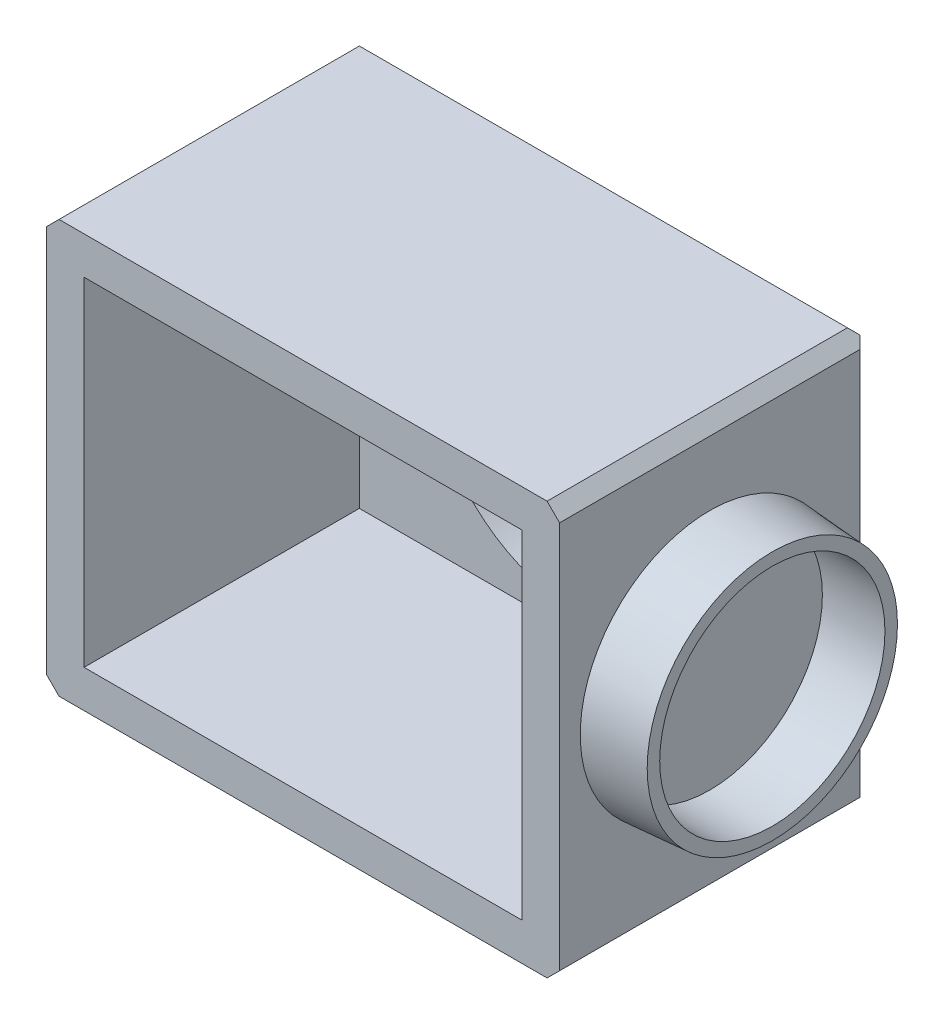
from build123d import *

# Parameters (mm, degrees)
SKETCH_1_W          = 41
SKETCH_1_H          = 33
SKETCH_1_W_2        = 35
SKETCH_1_H_2        = 27
EXTRUDE_1_DEPTH     = 22
SKETCH_6_W          = 41
SKETCH_6_H          = 33
EXTRUDE_1_2_DEPTH   = 3
SKETCH_7_R          = 12
CUT_EXTRUDE_1_DEPTH = 5
CHAMFER_1_SIZE      = 1
CHAMFER_2_SIZE      = 1
CHAMFER_3_SIZE      = 1
CHAMFER_4_SIZE      = 1
SKETCH_8_R          = 1.1
EXTRUDE_3_DEPTH     = 6
EXTRUDE_3_TAPER     = 3
CHAMFER_5_SIZE      = 1
CHAMFER_6_SIZE      = 1
CHAMFER_7_SIZE      = 1
CHAMFER_8_SIZE      = 1
SKETCH_9_R          = 10.35
EXTRUDE_4_DEPTH     = 5
EXTRUDE_4_TAPER     = 4
SKETCH_10_R         = 9
CUT_EXTRUDE_2_DEPTH = 5


with BuildPart() as part:
    # Эскиз1 → Extrude 1 (new body)
    with BuildSketch(Plane.XY):
        Rectangle(SKETCH_1_W, SKETCH_1_H)
        Rectangle(SKETCH_1_W_2, SKETCH_1_H_2, mode=Mode.SUBTRACT)
    extrude(amount=EXTRUDE_1_DEPTH)

    # Эскиз6 → Extrude 1 2 (add)
    with BuildSketch(Plane(origin=(0, 0, 0), x_dir=(-1, 0, 0), z_dir=(0, 0, -1))):
        Rectangle(SKETCH_6_W, SKETCH_6_H)
    extrude(amount=EXTRUDE_1_2_DEPTH)

    # Эскиз7 → Вырез-Вытянуть1 (cut)
    with BuildSketch(Plane(origin=(0, 0, -3), x_dir=(-1, 0, 0), z_dir=(0, 0, -1))):
        Circle(SKETCH_7_R)
    extrude(amount=-CUT_EXTRUDE_1_DEPTH, mode=Mode.SUBTRACT)

    # Фаска1
    chamfer_1_edges = [part.edges().sort_by_distance(p)[0] for p in [
        (0, 16.5, -3),
    ]]
    chamfer(chamfer_1_edges, length=CHAMFER_1_SIZE)

    # Фаска2
    chamfer_2_edges = [part.edges().sort_by_distance(p)[0] for p in [
        (20.5, -0.5, -3),
    ]]
    chamfer(chamfer_2_edges, length=CHAMFER_2_SIZE)

    # Фаска3
    chamfer_3_edges = [part.edges().sort_by_distance(p)[0] for p in [
        (-20.5, -0.5, -3),
    ]]
    chamfer(chamfer_3_edges, length=CHAMFER_3_SIZE)

    # Фаска4
    chamfer_4_edges = [part.edges().sort_by_distance(p)[0] for p in [
        (0, -16.5, -3),
    ]]
    chamfer(chamfer_4_edges, length=CHAMFER_4_SIZE)

    # Эскиз8 → Бобышка-Вытянуть3 (add)
    with BuildSketch(Plane.XY):
        with Locations((14.5, 0)):
            Circle(SKETCH_8_R)
        with Locations((-14.5, 0)):
            Circle(SKETCH_8_R)
    extrude(amount=EXTRUDE_3_DEPTH, taper=EXTRUDE_3_TAPER)

    # Фаска5
    chamfer_5_edges = [part.edges().sort_by_distance(p)[0] for p in [
        (-20.5, 16.5, 10),
    ]]
    chamfer(chamfer_5_edges, length=CHAMFER_5_SIZE)

    # Фаска6
    chamfer_6_edges = [part.edges().sort_by_distance(p)[0] for p in [
        (20.5, 16.5, 10),
    ]]
    chamfer(chamfer_6_edges, length=CHAMFER_6_SIZE)

    # Фаска7
    chamfer_7_edges = [part.edges().sort_by_distance(p)[0] for p in [
        (20.5, -16.5, 10),
    ]]
    chamfer(chamfer_7_edges, length=CHAMFER_7_SIZE)

    # Фаска8
    chamfer_8_edges = [part.edges().sort_by_distance(p)[0] for p in [
        (-20.5, -16.5, 10),
    ]]
    chamfer(chamfer_8_edges, length=CHAMFER_8_SIZE)

    # Эскиз9 → Бобышка-Вытянуть4 (add)
    with BuildSketch(Plane(origin=(20.5, 0, 0), x_dir=(0, 0, -1), z_dir=(1, 0, 0))):
        with Locations((-10, 0)):
            Circle(SKETCH_9_R)
    extrude(amount=EXTRUDE_4_DEPTH, taper=EXTRUDE_4_TAPER)

    # Эскиз10 → Вырез-Вытянуть2 (cut)
    with BuildSketch(Plane(origin=(25.5, 0, 0), x_dir=(0, 0, -1), z_dir=(1, 0, 0))):
        with Locations((-10, 0)):
            Circle(SKETCH_10_R)
    extrude(amount=-CUT_EXTRUDE_2_DEPTH, mode=Mode.SUBTRACT)


solid = part.part
